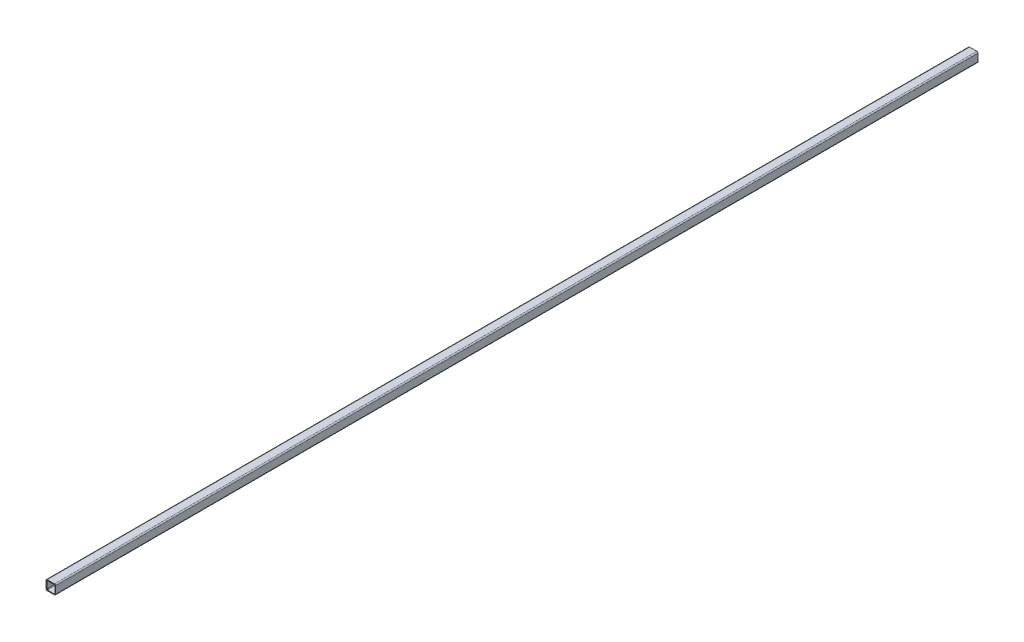
from build123d import *

# Parameters (mm, degrees)
SKETCH3_W                = 25.4
SKETCH3_H                = 25.4
SKETCH3_W_2              = 21.336
SKETCH3_H_2              = 21.336
BOSS_EXTRUDE1_DEPTH      = 1219.2
BOSS_EXTRUDE1_DEPTH_BACK = 1219.2
FILLET1_R                = 3.175
FILLET2_R                = 1.5875


with BuildPart() as part:
    # Sketch3 → Boss-Extrude1 (new body, two sides)
    with BuildSketch(Plane.XY) as boss_extrude1_sk:
        Rectangle(SKETCH3_W, SKETCH3_H)
        Rectangle(SKETCH3_W_2, SKETCH3_H_2, mode=Mode.SUBTRACT)
    extrude(amount=BOSS_EXTRUDE1_DEPTH)
    extrude(boss_extrude1_sk.sketch, amount=-BOSS_EXTRUDE1_DEPTH_BACK)

    # Fillet1
    fillet1_edges = [part.edges().sort_by_distance(p)[0] for p in [
        (12.7, -12.7, 0),
        (-12.7, -12.7, 0),
        (-12.7, 12.7, 0),
        (12.7, 12.7, 0),
    ]]
    fillet(fillet1_edges, radius=FILLET1_R)

    # Fillet2
    fillet2_edges = [part.edges().sort_by_distance(p)[0] for p in [
        (10.668, -10.668, 0),
        (10.668, 10.668, 0),
        (-10.668, 10.668, 0),
        (-10.668, -10.668, 0),
    ]]
    fillet(fillet2_edges, radius=FILLET2_R)


solid = part.part
